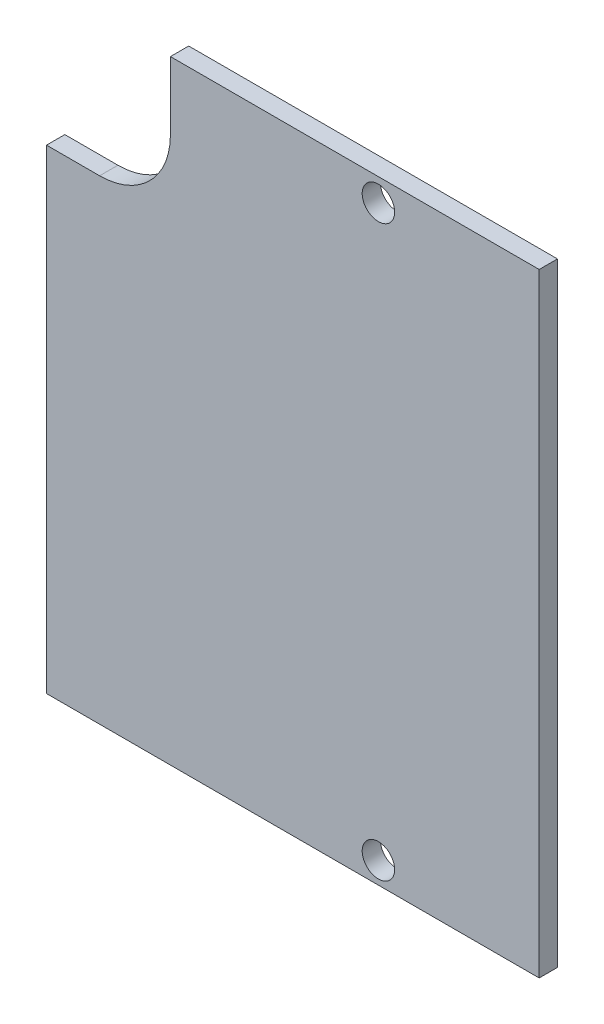
from build123d import *

# Parameters (mm, degrees)
SKETCH1_R           = 1.397
BOSS_EXTRUDE1_DEPTH = 1.5748


with BuildPart() as part:
    # Sketch1 → Boss-Extrude1 (new body)
    with BuildSketch(Plane.XY):
        with BuildLine():
            Line((0, 0), (0, 52.832))
            Line((0, 52.832), (-31.75, 52.832))
            Line((-31.75, 52.832), (-31.75, 46.99))
            ThreePointArc((-31.75, 46.99), (-33.535477062, 42.679477062), (-37.846, 40.894))
            Line((-37.846, 40.894), (-42.418, 40.894))
            Line((-42.418, 40.894), (-42.418, 0))
            Line((-42.418, 0), (0, 0))
        make_face()
        with Locations((-13.843, 50.8762)):
            Circle(SKETCH1_R, mode=Mode.SUBTRACT)
        with Locations((-13.843, 1.8542)):
            Circle(SKETCH1_R, mode=Mode.SUBTRACT)
    extrude(amount=BOSS_EXTRUDE1_DEPTH)


solid = part.part
